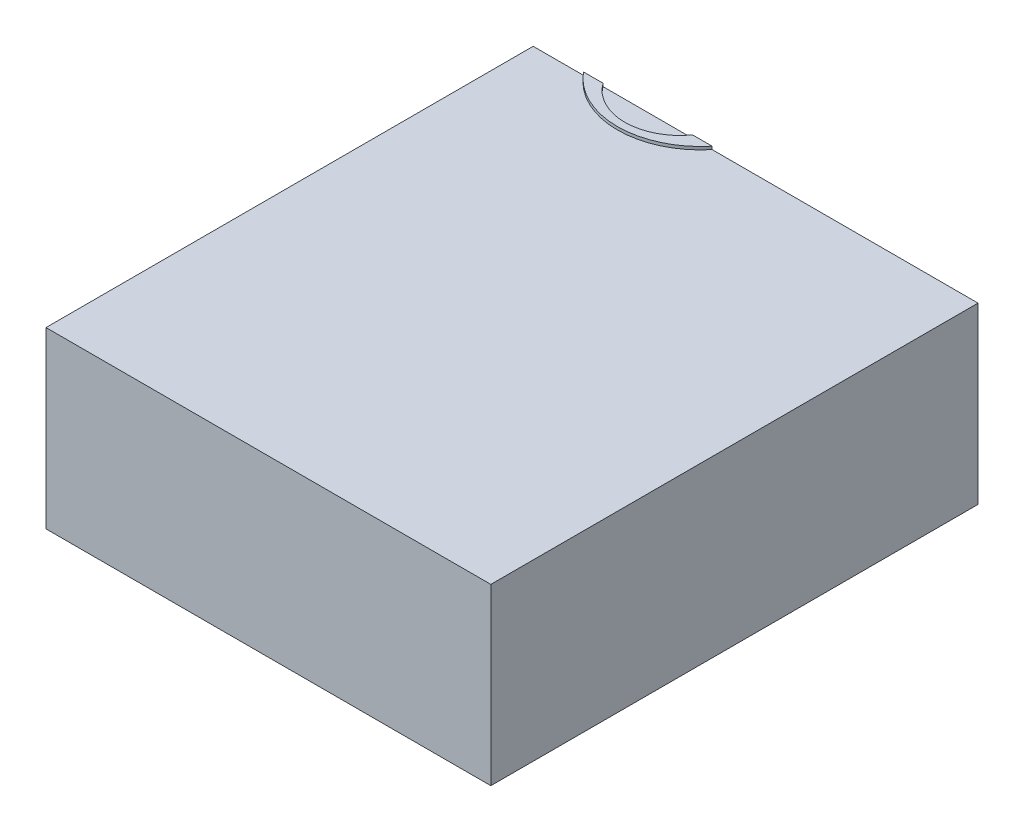
from build123d import *

# Parameters (mm, degrees)
SKETCH1_R           = 28.1
BOSS_EXTRUDE1_DEPTH = 1
SKETCH2_R           = 18.6
CUT_EXTRUDE1_DEPTH  = 58.8
SKETCH3_W           = 222.683092022
SKETCH3_H           = 364.2827524
BOSS_EXTRUDE2_DEPTH = 58.8
SKETCH4_W           = 207.917403516
SKETCH4_H           = 348.54429772
CUT_EXTRUDE2_DEPTH  = 55.8
SKETCH9_R           = 3
CUT_EXTRUDE8_DEPTH  = 10
SKETCH10_R          = 3.75
CUT_EXTRUDE9_DEPTH  = 10
CUT_EXTRUDE14_DEPTH = 500
SKETCH6_R           = 3.75
CUT_EXTRUDE5_DEPTH  = 400
SKETCH8_R           = 10
CUT_EXTRUDE7_DEPTH  = 10


with BuildPart() as part:
    # Sketch1 → Boss-Extrude1 (new body)
    with BuildSketch(Plane(origin=(0, 0, 0), x_dir=(1, 0, 0), z_dir=(0, 1, 0))):
        Circle(SKETCH1_R)
    extrude(amount=BOSS_EXTRUDE1_DEPTH)

    # Sketch2 → Cut-Extrude1 (cut)
    with BuildSketch(Plane(origin=(0, 1, 0), x_dir=(1, 0, 0), z_dir=(0, 1, 0))):
        with Locations((0, -7)):
            Circle(SKETCH2_R)
    extrude(amount=-CUT_EXTRUDE1_DEPTH, mode=Mode.SUBTRACT)

    # Sketch3 → Boss-Extrude2 (add)
    with BuildSketch(Plane(origin=(0, 0, 0), x_dir=(-1, 0, 0), z_dir=(0, -1, 0))):
        Rectangle(SKETCH3_W, SKETCH3_H)
    extrude(amount=BOSS_EXTRUDE2_DEPTH)

    # Sketch4 → Cut-Extrude2 (cut)
    with BuildSketch(Plane(origin=(0, -58.8, 0), x_dir=(-1, 0, 0), z_dir=(0, -1, 0))):
        Rectangle(SKETCH4_W, SKETCH4_H)
    extrude(amount=-CUT_EXTRUDE2_DEPTH, mode=Mode.SUBTRACT)

    # Sketch9 → Cut-Extrude8 (cut)
    with BuildSketch(Plane(origin=(0, 0, 0), x_dir=(1, 0, 0), z_dir=(0, 1, 0))):
        with Locations((0, -7)):
            Circle(SKETCH9_R)
    extrude(amount=-CUT_EXTRUDE8_DEPTH, mode=Mode.SUBTRACT)

    # Sketch10 → Cut-Extrude9 (cut)
    with BuildSketch(Plane(origin=(0, 1, 0), x_dir=(1, 0, 0), z_dir=(0, 1, 0))):
        with Locations((0, 19.85)):
            Circle(SKETCH10_R)
    extrude(amount=-CUT_EXTRUDE9_DEPTH, mode=Mode.SUBTRACT)

    # Sketch11 → Cut-Extrude14 (cut)
    with BuildSketch(Plane(origin=(0, -58.8, 0), x_dir=(-1, 0, 0), z_dir=(0, -1, 0))):
        Polygon((38.658453989, -17.8586238), (-111.341546011, -17.8586238), (-111.341546011, 182.1413762), (111.341546011, 182.1413762), (111.341546011, -182.1413762), (38.658453989, -182.1413762), align=None)
    extrude(amount=-CUT_EXTRUDE14_DEPTH, mode=Mode.SUBTRACT)

    # Sketch6 → Cut-Extrude5 (cut)
    with BuildSketch(Plane(origin=(0, 1, 0), x_dir=(1, 0, 0), z_dir=(0, 1, 0))):
        with Locations((0, 18.75)):
            Circle(SKETCH6_R)
    extrude(amount=-CUT_EXTRUDE5_DEPTH, mode=Mode.SUBTRACT)

    # Sketch8 → Cut-Extrude7 (cut)
    with BuildSketch(Plane(origin=(0, 0, -182.1413762), x_dir=(-1, 0, 0), z_dir=(0, 0, -1))):
        with Locations((-86.573671766, -25.011155335)):
            Circle(SKETCH8_R)
    extrude(amount=-CUT_EXTRUDE7_DEPTH, mode=Mode.SUBTRACT)


solid = part.part
